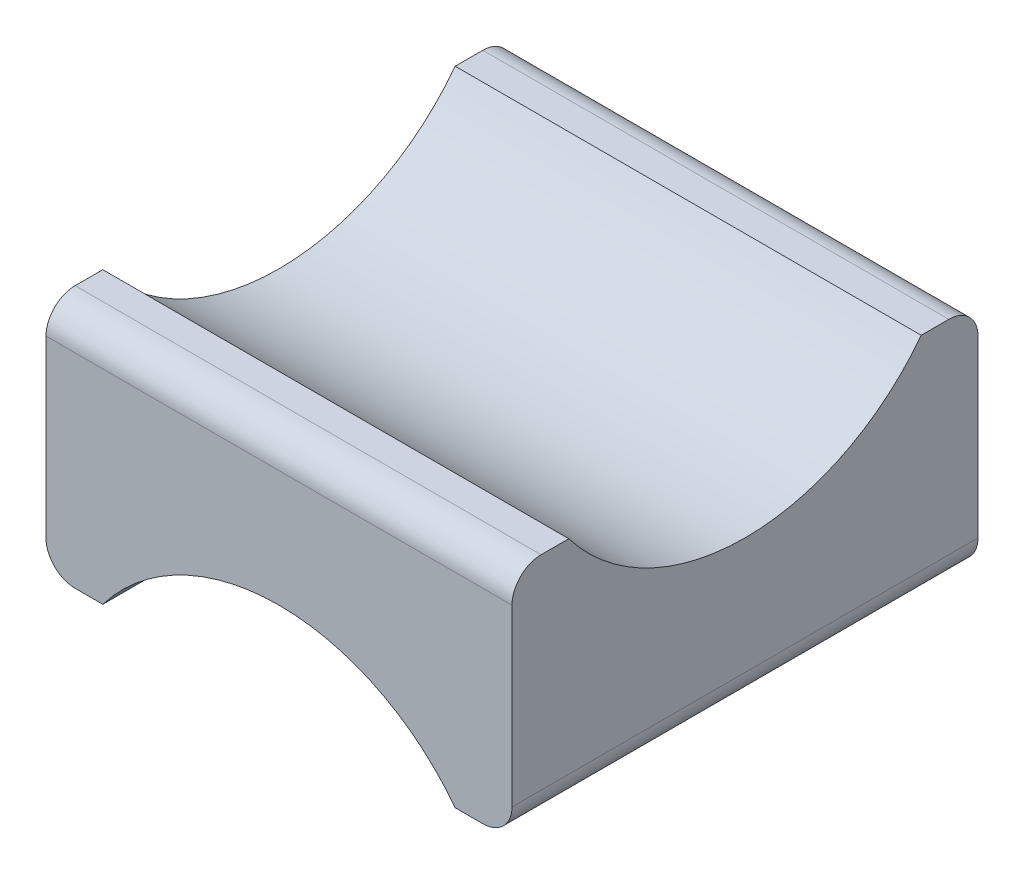
from build123d import *

# Parameters (mm, degrees)
BOSS_EXTRUDE1_DEPTH = 8
SKETCH2_R           = 7.6
CUT_EXTRUDE1_DEPTH  = 26
FILLET1_R           = 1


with BuildPart() as part:
    # Sketch1 → Boss-Extrude1 (new body, symmetric)
    with BuildSketch(Plane.XY):
        with BuildLine():
            Line((8, 4), (-8, 4))
            Line((-8, 4), (-8, -4))
            Line((-8, -4), (-6.049793385, -4))
            ThreePointArc((-6.049793385, -4), (0, -1), (6.049793385, -4))
            Line((6.049793385, -4), (8, -4))
            Line((8, -4), (8, 4))
        make_face()
    extrude(amount=BOSS_EXTRUDE1_DEPTH, both=True)

    # Sketch2 → Cut-Extrude1 (cut)
    with BuildSketch(Plane.ZY.offset(8)):
        with Locations((0, 8.6)):
            Circle(SKETCH2_R)
    extrude(amount=-CUT_EXTRUDE1_DEPTH, mode=Mode.SUBTRACT)

    # Fillet1
    fillet1_edges = [part.edges().sort_by_distance(p)[0] for p in [
        (8, -4, 0),
        (-8, -4, 0),
        (0, 4, -8),
        (0, 4, 8),
    ]]
    fillet(fillet1_edges, radius=FILLET1_R)


solid = part.part
